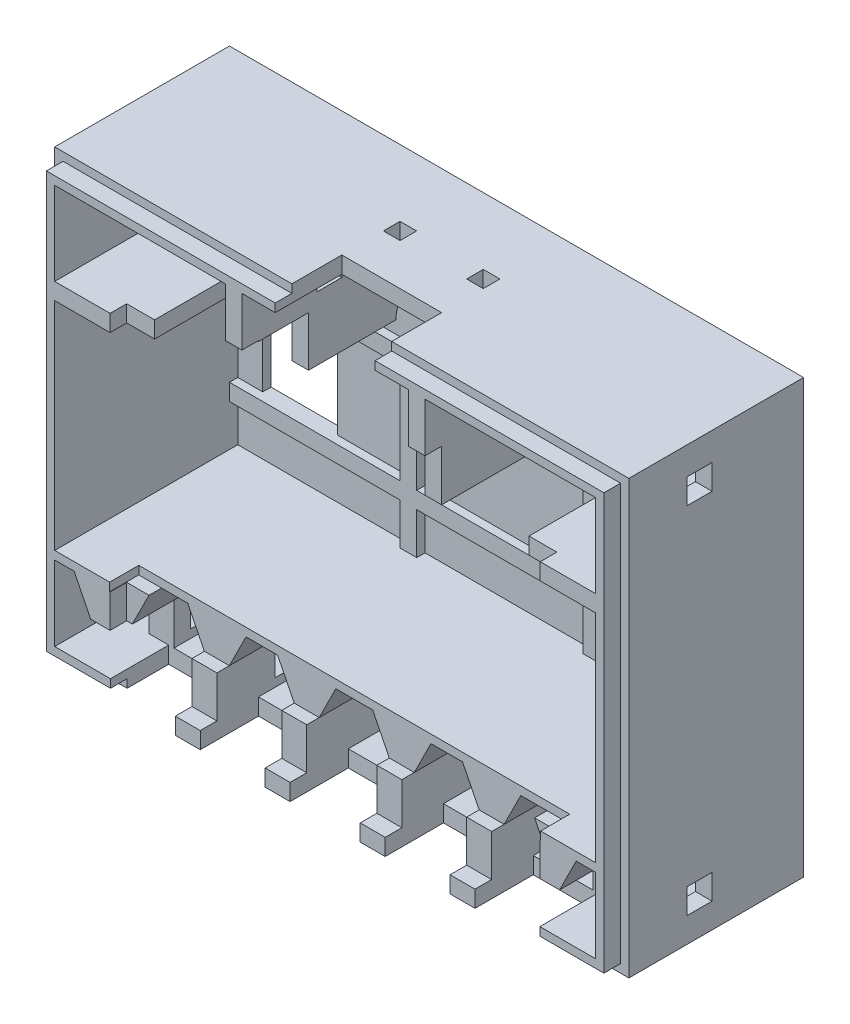
from build123d import *

# Parameters (mm, degrees)
SKICA1_W                    = 69
SKICA1_H                    = 52
SKICA1_W_2                  = 65
SKICA1_H_2                  = 48
VYSUNOUT_TENKOST_NN_1_DEPTH = 23
SKICA2_W                    = 10
SKICA2_H                    = 2
SKICA2_W_2                  = 2
SKICA2_H_2                  = 12
P_IDAT_EBRA_DEPTH           = 23
SKICA3_W                    = 2
SKICA3_H                    = 6
SKICA3_W_2                  = 12
SKICA3_H_2                  = 2
ODEBRAT_8_MM_DEPTH          = 8
SKICA4_W                    = 8.43
SKICA4_H                    = 2
SKICA4_W_2                  = 7.795
ODEBRAT_7_MM_DEPTH          = 7
ODEBRAT_3_5_MM_DEPTH        = 3.5
SKICA6_W                    = 51.7
SKICA6_H                    = 42.1
ODEBRAT_2_MM_DEPTH          = 2
SKICA8_W                    = 69
SKICA8_H                    = 52
P_IDAT_DNO_DEPTH            = 1
SKICA9_W                    = 2
SKICA9_H                    = 21
SKICA9_W_2                  = 65
SKICA9_H_2                  = 2
P_IDAT_EBRA_DNO_DEPTH       = 2
SKICA10_W                   = 9
SKICA10_H                   = 12
ODEBRAT_VYP_NA_DEPTH        = 24
P_IDAT_H_EK_DEPTH           = 2
SKICA12_W                   = 3
SKICA12_H                   = 3
ODEBRAT_VYSUNUT_M1_DEPTH    = 24.5
SKICA13_W                   = 3
SKICA13_H                   = 3
ODEBRAT_VYSUNUT_M2_DEPTH    = 24.5
ODEBRAT_VYSUNUT_M3_REACH    = 54
SKICA14_W                   = 2
SKICA14_H                   = 2
ODEBRAT_VYSUNUT_M4_DEPTH    = 24


with BuildPart() as part:
    # Skica1 → Vysunout tenkost_nn_1 (new body)
    with BuildSketch(Plane.XY):
        Rectangle(SKICA1_W, SKICA1_H)
        Rectangle(SKICA1_W_2, SKICA1_H_2, mode=Mode.SUBTRACT)
    extrude(amount=VYSUNOUT_TENKOST_NN_1_DEPTH)

    # Skica2 → P_idat _ebra (add)
    with BuildSketch(Plane.XY):
        Polygon((-32.5, -15), (-32.5, -14), (32.5, -14), (32.5, -15), (30.17, -15), (28.17, -19), (28.17, -24), (25.17, -24), (25.17, -19), (23.17, -15), (20.01, -15), (18.01, -19), (18.01, -24), (15.01, -24), (15.01, -19), (13.01, -15), (9.215, -15), (7.215, -19), (7.215, -24), (4.215, -24), (4.215, -19), (2.215, -15), (-2.215, -15), (-4.215, -19), (-4.215, -24), (-7.215, -24), (-7.215, -19), (-9.215, -15), (-13.01, -15), (-15.01, -19), (-15.01, -24), (-18.01, -24), (-18.01, -19), (-20.01, -15), (-23.17, -15), (-25.17, -19), (-25.17, -24), (-28.17, -24), (-28.17, -19), (-30.17, -15), align=None)
        with Locations((-27.5, 13)):
            Rectangle(SKICA2_W, SKICA2_H)
        with Locations((27.5, 13)):
            Rectangle(SKICA2_W, SKICA2_H)
        with Locations((11, 18)):
            Rectangle(SKICA2_W_2, SKICA2_H_2)
        with Locations((-11, 18)):
            Rectangle(SKICA2_W_2, SKICA2_H_2)
    extrude(amount=P_IDAT_EBRA_DEPTH)

    # Skica3 → Odebrat 8 mm (cut)
    with BuildSketch(Plane.XY.offset(23)):
        with Locations((-11, 15)):
            Rectangle(SKICA3_W, SKICA3_H)
        with Locations((0, 25)):
            Rectangle(SKICA3_W_2, SKICA3_H_2)
    extrude(amount=-ODEBRAT_8_MM_DEPTH, mode=Mode.SUBTRACT)

    # Skica4 → Odebrat 7 mm (cut)
    with BuildSketch(Plane.XY.offset(23)):
        with Locations((0, -25)):
            Rectangle(SKICA4_W, SKICA4_H)
        with Locations((11.1125, -25)):
            Rectangle(SKICA4_W_2, SKICA4_H)
        with Locations((-11.1125, -25)):
            Rectangle(SKICA4_W_2, SKICA4_H)
        Polygon((18.01, -24), (18.01, -26), (25.8, -26), (25.8, -24), (28.17, -24), (28.17, -19), (25.17, -19), (25.17, -24), align=None)
        Polygon((-18.01, -24), (-18.01, -26), (-25.8, -26), (-25.8, -24), (-28.17, -24), (-28.17, -19), (-25.17, -19), (-25.17, -24), align=None)
    extrude(amount=-ODEBRAT_7_MM_DEPTH, mode=Mode.SUBTRACT)

    # Skica5 → Odebrat 3_5 mm (cut)
    with BuildSketch(Plane.XY.offset(23)):
        Polygon((-25.9, -13), (25.9, -13), (25.9, -15), (20.01, -15), (20.01, -19), (-20.01, -19), (-20.01, -15), (-25.9, -15), align=None)
    extrude(amount=-ODEBRAT_3_5_MM_DEPTH, mode=Mode.SUBTRACT)

    # Skica6 → Odebrat 2 mm (cut)
    with BuildSketch(Plane.XY.offset(23)):
        with Locations((0, -2.95)):
            Rectangle(SKICA6_W, SKICA6_H)
        Polygon((-34.5, 26), (34.5, 26), (34.5, -26), (25.8, -26), (25.8, -25), (33.5, -25), (33.5, 25), (-33.5, 25), (-33.5, -25), (-25.8, -25), (-25.8, -26), (-34.5, -26), align=None)
    extrude(amount=-ODEBRAT_2_MM_DEPTH, mode=Mode.SUBTRACT)

    # Skica8 → P_idat dno (add)
    with BuildSketch(Plane.XY):
        Rectangle(SKICA8_W, SKICA8_H)
    extrude(amount=P_IDAT_DNO_DEPTH)

    # Skica9 → P_idat _ebra _dno (add)
    with BuildSketch(Plane.XY):
        with Locations((-11, -3.5)):
            Rectangle(SKICA9_W, SKICA9_H)
        with Locations((11, -3.5)):
            Rectangle(SKICA9_W, SKICA9_H)
        with Locations((0, 6)):
            Rectangle(SKICA9_W_2, SKICA9_H_2)
        with Locations((0, -8)):
            Rectangle(SKICA9_W_2, SKICA9_H_2)
    extrude(amount=P_IDAT_EBRA_DNO_DEPTH)

    # Skica10 → Odebrat vyp_na (cut, through all)
    with BuildSketch(Plane(origin=(0, 0, 0), x_dir=(-1, 0, 0), z_dir=(0, 0, -1))):
        with Locations((25, -1)):
            Rectangle(SKICA10_W, SKICA10_H)
    extrude(amount=-ODEBRAT_VYP_NA_DEPTH, mode=Mode.SUBTRACT)

    # Skica11 → P_idat h_ek (add)
    with BuildSketch(Plane(origin=(4.25, -4.25, 0), x_dir=(0.707106781, 0.707106781, 0), z_dir=(-0.707106781, 0.707106781, 0))):
        with BuildLine():
            Line((25.809397513, -1), (25.809397513, -11))
            Line((25.809397513, -11), (33.809397513, -11))
            Line((33.809397513, -11), (33.809397513, -9))
            ThreePointArc((33.809397513, -9), (29.566756826, -7.242640687), (27.809397513, -3))
            Line((27.809397513, -3), (27.809397513, -1))
            Line((27.809397513, -1), (25.809397513, -1))
        make_face()
    extrude(amount=-P_IDAT_H_EK_DEPTH)

    # Skica12 → Odebrat vysunut_m1 (cut)
    with BuildSketch(Plane(origin=(34.5, 0, 0), x_dir=(0, 0, -1), z_dir=(1, 0, 0))):
        with Locations((-12.5, 21.156854249)):
            Rectangle(SKICA12_W, SKICA12_H)
        with Locations((-12.5, -21.5)):
            Rectangle(SKICA12_W, SKICA12_H)
    extrude(amount=-ODEBRAT_VYSUNUT_M1_DEPTH, mode=Mode.SUBTRACT)

    # Skica13 → Odebrat vysunut_m2 (cut)
    with BuildSketch(Plane.ZY.offset(34.5)):
        with Locations((12.5, 21.156854249)):
            Rectangle(SKICA13_W, SKICA13_H)
        with Locations((12.5, -21.5)):
            Rectangle(SKICA13_W, SKICA13_H)
    extrude(amount=-ODEBRAT_VYSUNUT_M2_DEPTH, mode=Mode.SUBTRACT)

    # Skica14 → Odebrat vysunut_m3 (cut, up to next)
    with BuildSketch(Plane(origin=(0, 26, 0), x_dir=(1, 0, 0), z_dir=(0, 1, 0)), mode=Mode.PRIVATE) as odebrat_vysunut_m3_sk1:
        with Locations((5, -9)):
            Rectangle(SKICA14_W, SKICA14_H)
    odebrat_vysunut_m3_tool1 = extrude(odebrat_vysunut_m3_sk1.sketch, amount=-ODEBRAT_VYSUNUT_M3_REACH, mode=Mode.PRIVATE) & part.part
    add(odebrat_vysunut_m3_tool1.solids().sort_by_distance((5, 26, 9))[0], mode=Mode.SUBTRACT)
    # Skica14 → Odebrat vysunut_m3 (cut, up to next)
    with BuildSketch(Plane(origin=(0, 26, 0), x_dir=(1, 0, 0), z_dir=(0, 1, 0)), mode=Mode.PRIVATE) as odebrat_vysunut_m3_sk2:
        with Locations((-5, -9)):
            Rectangle(SKICA14_W, SKICA14_H)
    odebrat_vysunut_m3_tool2 = extrude(odebrat_vysunut_m3_sk2.sketch, amount=-ODEBRAT_VYSUNUT_M3_REACH, mode=Mode.PRIVATE) & part.part
    add(odebrat_vysunut_m3_tool2.solids().sort_by_distance((-5, 26, 9))[0], mode=Mode.SUBTRACT)

    # Skica15 → Odebrat vysunut_m4 (cut)
    with BuildSketch(Plane(origin=(12, 0, 0), x_dir=(0, 0, -1), z_dir=(1, 0, 0))):
        with BuildLine():
            Line((-1, 15.5), (-1, 12))
            Line((-1, 12), (-4.5, 12))
            ThreePointArc((-4.5, 12), (-3.474873734, 14.474873734), (-1, 15.5))
        make_face()
    extrude(amount=-ODEBRAT_VYSUNUT_M4_DEPTH, mode=Mode.SUBTRACT)


solid = part.part
